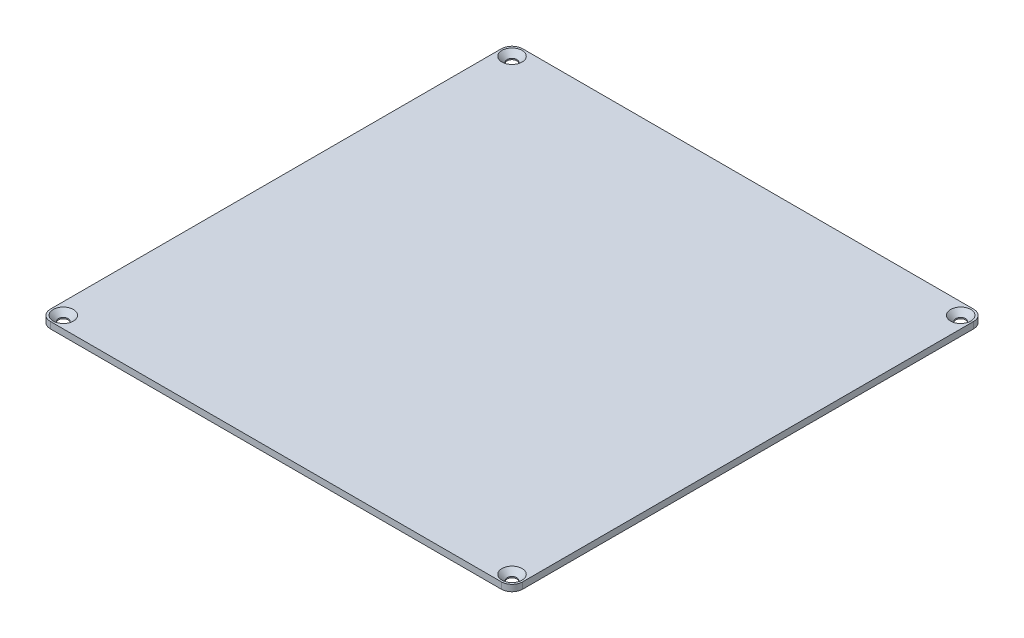
from build123d import *

# Parameters (mm, degrees)
SKETCH1_W                                    = 220
SKETCH1_H                                    = 220
BOSS_EXTRUDE1_DEPTH                          = 3
FILLET1_R                                    = 5
CSK_FOR_M4_COUNTERSUNK_FLAT_HEAD_SCR_2_COUNT = 2
CSK_FOR_M4_COUNTERSUNK_FLAT_HEAD_SCR_2_PITCH = 209
CSK_FOR_M4_COUNTERSUNK_FLAT_HEAD_SCR_3_COUNT = 2
CSK_FOR_M4_COUNTERSUNK_FLAT_HEAD_SCR_3_PITCH = 209
CSK_FOR_M4_COUNTERSUNK_FLAT_HEAD_SCR_4_COUNT = 2
CSK_FOR_M4_COUNTERSUNK_FLAT_HEAD_SCR_4_PITCH = 295.570634536


with BuildPart() as part:
    # Sketch1 → Boss-Extrude1 (new body)
    with BuildSketch(Plane(origin=(0, 0, 0), x_dir=(1, 0, 0), z_dir=(0, 1, 0))):
        Rectangle(SKETCH1_W, SKETCH1_H)
    extrude(amount=BOSS_EXTRUDE1_DEPTH)

    # Fillet1
    fillet1_edges = [part.edges().sort_by_distance(p)[0] for p in [
        (110, 1.5, 110),
        (-110, 1.5, 110),
        (-110, 1.5, -110),
        (110, 1.5, -110),
    ]]
    fillet(fillet1_edges, radius=FILLET1_R)

    # Sketch4 → CSK for M4 Countersunk Flat Head Screw1 (revolve, cut)
    with BuildSketch(Plane(origin=(-104.5, 3, -104.5), x_dir=(0, 0, 1), z_dir=(1, 0, 0))):
        Polygon((0, 0), (0, 3), (2.25, 3), (2.25, 2.45), (4.7, 0), align=None)
    csk_for_m4_countersunk_flat_head_screw1 = revolve(axis=Axis((-104.5, 9.35, -104.5), (0, -1, 0)), mode=Mode.SUBTRACT)

    # CSK for M4 Countersunk Flat Head Scr 2: CSK for M4 Countersunk Flat Head Screw1 ×2
    with Locations(*[(i * CSK_FOR_M4_COUNTERSUNK_FLAT_HEAD_SCR_2_PITCH, 0, 0) for i in range(1, CSK_FOR_M4_COUNTERSUNK_FLAT_HEAD_SCR_2_COUNT)]):
        add(csk_for_m4_countersunk_flat_head_screw1, mode=Mode.SUBTRACT)

    # CSK for M4 Countersunk Flat Head Scr 3: CSK for M4 Countersunk Flat Head Screw1 ×2
    with Locations(*[(0, 0, i * CSK_FOR_M4_COUNTERSUNK_FLAT_HEAD_SCR_3_PITCH) for i in range(1, CSK_FOR_M4_COUNTERSUNK_FLAT_HEAD_SCR_3_COUNT)]):
        add(csk_for_m4_countersunk_flat_head_screw1, mode=Mode.SUBTRACT)

    # CSK for M4 Countersunk Flat Head Scr 4: CSK for M4 Countersunk Flat Head Screw1 ×2
    with Locations(*[Vector(0.707106781, 0, 0.707106781) * (i * CSK_FOR_M4_COUNTERSUNK_FLAT_HEAD_SCR_4_PITCH) for i in range(1, CSK_FOR_M4_COUNTERSUNK_FLAT_HEAD_SCR_4_COUNT)]):
        add(csk_for_m4_countersunk_flat_head_screw1, mode=Mode.SUBTRACT)


solid = part.part
